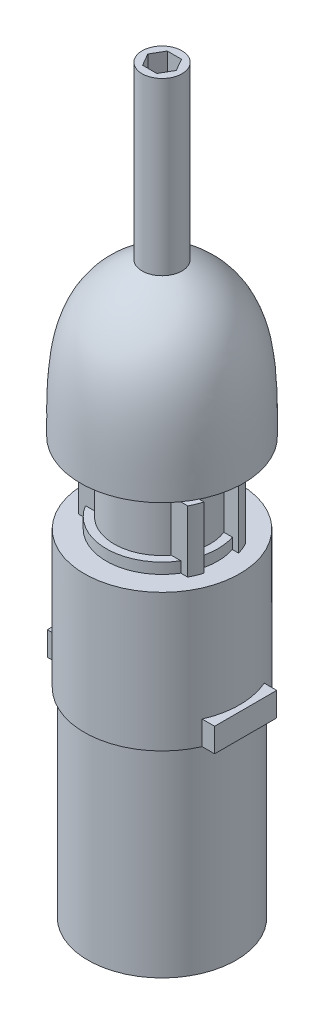
from build123d import *

# Parameters (mm, degrees)
SKETCH1_R              = 14
BOSS_EXTRUDE1_DEPTH    = 2.7
SKETCH2_R              = 12
BOSS_EXTRUDE2_DEPTH    = 15.5
BOSS_EXTRUDE3_DEPTH    = 15.5
SKETCH4_R              = 19.5
BOSS_EXTRUDE4_DEPTH    = 34.5
SKETCH5_W              = 42
SKETCH5_H              = 15.6
BOSS_EXTRUDE5_DEPTH    = 6
SKETCH6_R              = 18.6
BOSS_EXTRUDE6_DEPTH    = 50
SPLIT1_SURFACE_1_BACK  = 196.041
SPLIT1_SURFACE_1_DEPTH = 392.082
SPLIT1_SURFACE_2_BACK  = 196.041
SPLIT1_SURFACE_2_DEPTH = 392.082
CUT_EXTRUDE1_DEPTH     = 11.2


with BuildPart() as part:
    # Sketch1 → Boss-Extrude1 (new body)
    with BuildSketch(Plane(origin=(0, 0, 0), x_dir=(1, 0, 0), z_dir=(0, 1, 0))):
        with Locations(Location((0, 0, 0), (0, 0, 90))):
            Circle(SKETCH1_R)
    extrude(amount=BOSS_EXTRUDE1_DEPTH)

    # Sketch2 → Boss-Extrude2 (add)
    with BuildSketch(Plane(origin=(0, 0, 0), x_dir=(1, 0, 0), z_dir=(0, 1, 0))):
        with Locations(Location((0, 0, 0), (0, 0, 270))):
            Circle(SKETCH2_R)
    extrude(amount=BOSS_EXTRUDE2_DEPTH)

    # Sketch3 → Boss-Extrude3 (add)
    with BuildSketch(Plane(origin=(0, 0, 0), x_dir=(1, 0, 0), z_dir=(0, 1, 0))):
        with BuildLine():
            ThreePointArc((13.699908759, 7.25), (14.361878956, 5.829788405), (14.877079687, 4.35))
            Line((14.877079687, 4.35), (-14.877079687, 4.35))
            ThreePointArc((-14.877079687, 4.35), (-14.361878956, 5.829788405), (-13.699908759, 7.25))
            Line((-13.699908759, 7.25), (13.699908759, 7.25))
        make_face()
        with BuildLine():
            ThreePointArc((-13.699908759, -7.25), (-14.361878956, -5.829788405), (-14.877079687, -4.35))
            Line((-14.877079687, -4.35), (14.877079687, -4.35))
            ThreePointArc((14.877079687, -4.35), (14.361878956, -5.829788405), (13.699908759, -7.25))
            Line((13.699908759, -7.25), (-13.699908759, -7.25))
        make_face()
    extrude(amount=BOSS_EXTRUDE3_DEPTH)

    # Sketch4 → Boss-Extrude4 (add)
    with BuildSketch(Plane.XZ):
        with Locations(Location((0, 0, 0), (0, 0, 270))):
            Circle(SKETCH4_R)
    extrude(amount=BOSS_EXTRUDE4_DEPTH)

    # Sketch5 → Boss-Extrude5 (add)
    with BuildSketch(Plane.XZ.offset(34.5)):
        Rectangle(SKETCH5_W, SKETCH5_H)
    extrude(amount=-BOSS_EXTRUDE5_DEPTH)


with BuildPart() as body_2:
    # Sketch6 → Boss-Extrude6 (new body)
    with BuildSketch(Plane.XZ.offset(34.5)):
        with Locations(Location((0, 0, 0), (0, 0, 270))):
            Circle(SKETCH6_R)
    extrude(amount=BOSS_EXTRUDE6_DEPTH)


with BuildPart() as body_3:
    # Sketch7 → Revolve1 (revolve)
    with BuildSketch(Plane.XY, mode=Mode.PRIVATE) as revolve1_sk:
        with BuildLine():
            Line((0, 15.5), (0, 20.2))
            Line((0, 20.2), (0, 101.5))
            Line((0, 101.5), (5, 101.5))
            Line((5, 101.5), (5, 58.6))
            add(Edge.make_bspline(
                [(20.5, 20.2), (20.474499301, 37.432747691), (20.866112575, 50.996454144), (5, 58.6)],
                knots=[0, 0, 0, 0, 1, 1, 1, 1], degree=3))
            Line((20.5, 20.2), (7.5, 20.2))
            Line((7.5, 20.2), (7.5, 15.5))
            Line((7.5, 15.5), (0, 15.5))
        make_face()
    revolve(revolve1_sk.sketch.rotate(Axis((0, 20.2, 0), (0, 1, 0)), 90), axis=Axis((0, 20.2, 0), (0, 1, 0)))


with BuildPart() as body_4:
    # Split1: the piece behind the surface
    add(body_3.part)
    # Split1 surface: a surface, the sketch's curves swept straight by 392.082 mm
    with BuildLine(Plane.XY.offset(-SPLIT1_SURFACE_1_BACK), mode=Mode.PRIVATE) as split1_surface_1_path:
        Line((5, 58.6), (-5, 58.6))
    split1_surface_1 = Shell.extrude(split1_surface_1_path.wire(), (0 * SPLIT1_SURFACE_1_DEPTH, 0 * SPLIT1_SURFACE_1_DEPTH, 1 * SPLIT1_SURFACE_1_DEPTH))
    split(bisect_by=split1_surface_1, keep=Keep.BOTTOM)

    # Sketch9 → Cut-Extrude1 (cut)
    with BuildSketch(Plane(origin=(0, 101.5, 0), x_dir=(1, 0, 0), z_dir=(0, 1, 0))):
        Polygon((3.579571669, 0), (1.789785834, 3.1), (-1.789785834, 3.1), (-3.579571669, 0), (-1.789785834, -3.1), (1.789785834, -3.1), align=None)
    extrude(amount=-CUT_EXTRUDE1_DEPTH, mode=Mode.SUBTRACT)


with BuildPart() as body_3_1:
    add(body_3.part)

    # Split1: split by a surface, the side it looks to stays
    # Split1 surface: a surface, the sketch's curves swept straight by 392.082 mm
    with BuildLine(Plane.XY.offset(-SPLIT1_SURFACE_2_BACK), mode=Mode.PRIVATE) as split1_surface_2_path:
        Line((5, 58.6), (-5, 58.6))
    split1_surface_2 = Shell.extrude(split1_surface_2_path.wire(), (0 * SPLIT1_SURFACE_2_DEPTH, 0 * SPLIT1_SURFACE_2_DEPTH, 1 * SPLIT1_SURFACE_2_DEPTH))
    split(bisect_by=split1_surface_2, keep=Keep.TOP)


solid = Compound([part.part, body_2.part, body_4.part, body_3_1.part])
